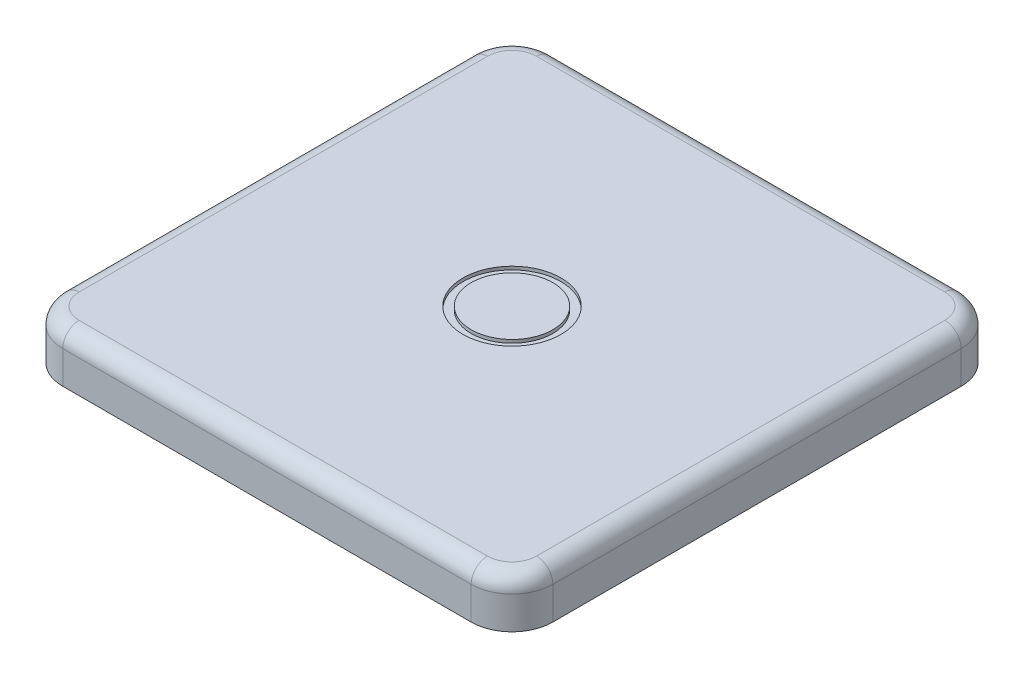
from build123d import *

# Parameters (mm, degrees)
SKETCH1_W           = 30
SKETCH1_H           = 30
BOSS_EXTRUDE1_DEPTH = 3
FILLET1_R           = 2.5
FILLET2_R           = 1
SKETCH2_R           = 3
SKETCH2_R_2         = 2.5
CUT_EXTRUDE1_DEPTH  = 0.2


with BuildPart() as part:
    # Sketch1 → Boss-Extrude1 (new body)
    with BuildSketch(Plane(origin=(0, 0, 0), x_dir=(1, 0, 0), z_dir=(0, 1, 0))):
        Rectangle(SKETCH1_W, SKETCH1_H)
    extrude(amount=BOSS_EXTRUDE1_DEPTH)

    # Fillet1
    fillet1_edges = [part.edges().sort_by_distance(p)[0] for p in [
        (15, 1.5, 15),
        (-15, 1.5, 15),
        (-15, 1.5, -15),
        (15, 1.5, -15),
    ]]
    fillet(fillet1_edges, radius=FILLET1_R)

    # Fillet2
    fillet2_edges = [part.edges().sort_by_distance(p)[0] for p in [
        (-15, 3, 0),
        (0, 3, -15),
        (15, 3, 0),
        (0, 3, 15),
        (14.267766953, 3, 14.267766953),
        (-14.267766953, 3, 14.267766953),
        (14.267766953, 3, -14.267766953),
        (-14.267766953, 3, -14.267766953),
    ]]
    fillet(fillet2_edges, radius=FILLET2_R)

    # Sketch2 → Cut-Extrude1 (cut)
    with BuildSketch(Plane(origin=(0, 3, 0), x_dir=(1, 0, 0), z_dir=(0, 1, 0))):
        Circle(SKETCH2_R)
        Circle(SKETCH2_R_2, mode=Mode.SUBTRACT)
    extrude(amount=-CUT_EXTRUDE1_DEPTH, mode=Mode.SUBTRACT)


solid = part.part
